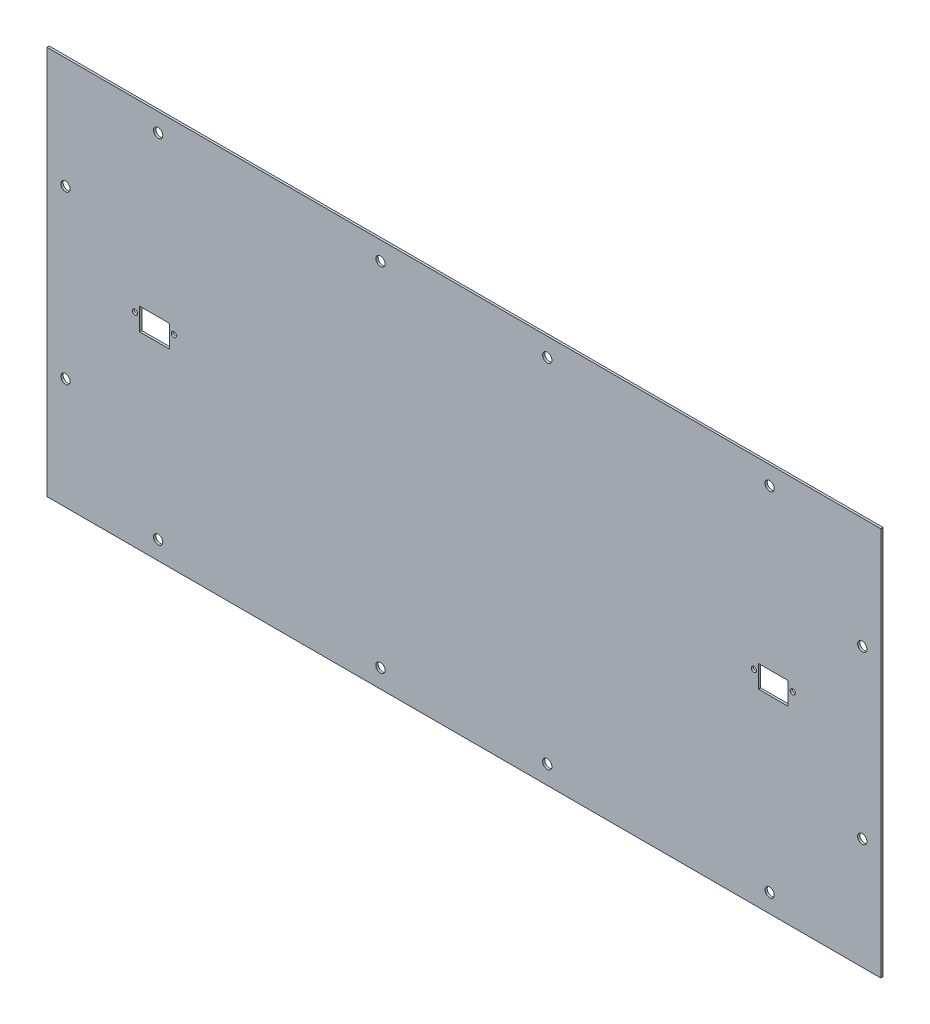
from build123d import *

# Parameters (mm, degrees)
SURFACE_EXTRUDE1_1_DEPTH = 450
THICKEN15_T2             = 1.2
SKETCH2_W                = 16
SKETCH2_H                = 12
CUT_EXTRUDE1_DEPTH       = 10
SKETCH3_R                = 1.4
CUT_EXTRUDE2_DEPTH       = 10
SKETCH4_R                = 2.5
CUT_EXTRUDE5_DEPTH       = 10


with BuildPart() as body_1:
    # Surface-Extrude1: a surface, the sketch's curves swept straight by 450 mm
    with BuildLine(Plane(origin=(0, 0, 0), x_dir=(0, 0, -1), z_dir=(1, 0, 0)), mode=Mode.PRIVATE) as surface_extrude1_1_path:
        Line((0, 0), (0, 210))
    surface_extrude1_1 = Shell.extrude(surface_extrude1_1_path.wire(), (1 * SURFACE_EXTRUDE1_1_DEPTH, 0 * SURFACE_EXTRUDE1_1_DEPTH, 0 * SURFACE_EXTRUDE1_1_DEPTH))
    add(Solid.thicken(surface_extrude1_1, -THICKEN15_T2))

    # Sketch2 → Cut-Extrude1 (cut)
    with BuildSketch(Plane(origin=(0, 0, -1.2), x_dir=(-1, 0, 0), z_dir=(0, 0, -1))):
        with Locations((-392, 108)):
            Rectangle(SKETCH2_W, SKETCH2_H)
        with Locations((-58, 108)):
            Rectangle(SKETCH2_W, SKETCH2_H)
    extrude(amount=-CUT_EXTRUDE1_DEPTH, mode=Mode.SUBTRACT)

    # Sketch3 → Cut-Extrude2 (cut)
    with BuildSketch(Plane(origin=(0, 0, -1.2), x_dir=(-1, 0, 0), z_dir=(0, 0, -1))):
        with Locations((-402.5, 110)):
            Circle(SKETCH3_R)
        with Locations((-381.5, 110)):
            Circle(SKETCH3_R)
        with Locations((-68.5, 110)):
            Circle(SKETCH3_R)
        with Locations((-47.5, 110)):
            Circle(SKETCH3_R)
    extrude(amount=-CUT_EXTRUDE2_DEPTH, mode=Mode.SUBTRACT)

    # Sketch4 → Cut-Extrude5 (cut)
    with BuildSketch(Plane(origin=(0, 0, -1.2), x_dir=(-1, 0, 0), z_dir=(0, 0, -1))):
        with Locations((-390, 200)):
            Circle(SKETCH4_R)
        with Locations((-270, 200)):
            Circle(SKETCH4_R)
        with Locations((-440, 150)):
            Circle(SKETCH4_R)
        with Locations((-180, 200)):
            Circle(SKETCH4_R)
        with Locations((-60, 200)):
            Circle(SKETCH4_R)
        with Locations((-10, 150)):
            Circle(SKETCH4_R)
        with Locations((-10, 60)):
            Circle(SKETCH4_R)
        with Locations((-60, 10)):
            Circle(SKETCH4_R)
        with Locations((-180, 10)):
            Circle(SKETCH4_R)
        with Locations((-270, 10)):
            Circle(SKETCH4_R)
        with Locations((-390, 10)):
            Circle(SKETCH4_R)
        with Locations((-440, 60)):
            Circle(SKETCH4_R)
    extrude(amount=-CUT_EXTRUDE5_DEPTH, mode=Mode.SUBTRACT)


solid = body_1.part
